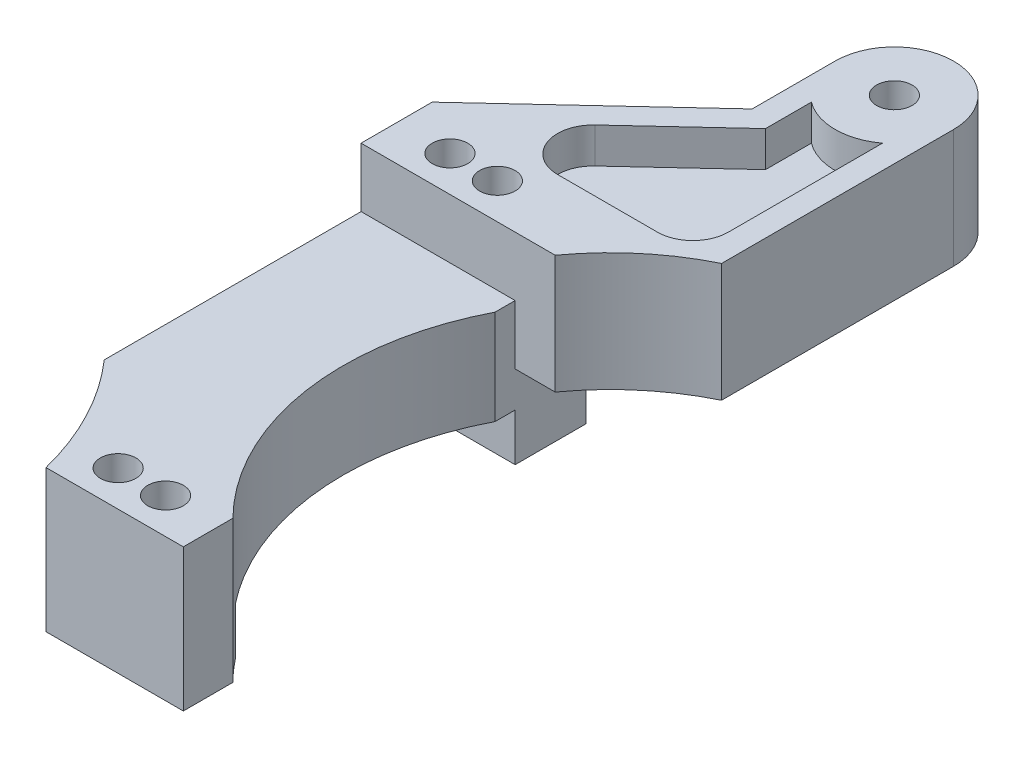
from build123d import *

# Parameters (mm, degrees)
SKETCH1_W               = 13
SKETCH1_H               = 6
SKETCH1_R               = 1.5
BOSS_EXTRUDE1_DEPTH     = 4
BOSS_EXTRUDE1_2_DEPTH   = 4
BOSS_EXTRUDE2_START     = 4
SKETCH1_4_R             = 1.5
SKETCH1_4_W             = 13
SKETCH1_4_H             = 6
BOSS_EXTRUDE2_DEPTH     = 8
SKETCH2_R               = 1.5
BOSS_EXTRUDE3_DEPTH     = 5
SKETCH2_3_R             = 1.5
BOSS_EXTRUDE4_DEPTH     = 5
CUT_EXTRUDE1_DEPTH      = 3
FILLET3_R               = 3
SKETCH4_R               = 20.5
CUT_EXTRUDE2_DEPTH      = 6
CUT_EXTRUDE2_DEPTH_BACK = 13


with BuildPart() as part:
    # Sketch1 → Boss-Extrude1 (new body)
    with BuildSketch(Plane(origin=(0, -9, 0), x_dir=(1, 0, 0), z_dir=(0, 1, 0))):
        with Locations((25.1, 41)):
            Rectangle(SKETCH1_W, SKETCH1_H)
        with Locations((27.1, 41)):
            Circle(SKETCH1_R, mode=Mode.SUBTRACT)
        with Locations((23.1, 41)):
            Circle(SKETCH1_R, mode=Mode.SUBTRACT)
    extrude(amount=BOSS_EXTRUDE1_DEPTH)



with BuildPart() as body_2:
    # Sketch1 → Boss-Extrude1 2 (new body)
    with BuildSketch(Plane(origin=(0, -9, 0), x_dir=(1, 0, 0), z_dir=(0, 1, 0))):
        with BuildLine():
            ThreePointArc((22.6, 10.089722494), (23.395394249, 8.075767946), (24.01171589, 6))
            Line((24.01171589, 6), (35.6, 6))
            Line((35.6, 6), (35.6, 10.18070798))
            ThreePointArc((35.6, 10.18070798), (34.768444056, 11.068532406), (33.986085046, 12))
            Line((33.986085046, 12), (31.6, 12))
            Line((31.6, 12), (22.6, 12))
            Line((22.6, 12), (22.6, 10.089722494))
        make_face()
        with Locations((27.1, 9)):
            Circle(SKETCH1_R, mode=Mode.SUBTRACT)
        with Locations((31.1, 9)):
            Circle(SKETCH1_R, mode=Mode.SUBTRACT)
    extrude(amount=BOSS_EXTRUDE1_2_DEPTH)


with BuildPart() as part_1:
    add(part.part)

    add(body_2.part)  # Boss-Extrude2 merges body 2
    # Sketch1_4 → Boss-Extrude2 (add)
    with BuildSketch(Plane(origin=(0, -9, 0), x_dir=(1, 0, 0), z_dir=(0, 1, 0)).offset(BOSS_EXTRUDE2_START)):
        with BuildLine():
            ThreePointArc((22.6, 10.089722494), (23.395394249, 8.075767946), (24.01171589, 6))
            Line((24.01171589, 6), (35.6, 6))
            Line((35.6, 6), (35.6, 10.18070798))
            ThreePointArc((35.6, 10.18070798), (34.768444056, 11.068532406), (33.986085046, 12))
            Line((33.986085046, 12), (31.6, 12))
            Line((31.6, 12), (22.6, 12))
            Line((22.6, 12), (22.6, 10.089722494))
        make_face()
        with Locations((27.1, 9)):
            Circle(SKETCH1_4_R, mode=Mode.SUBTRACT)
        with Locations((31.1, 9)):
            Circle(SKETCH1_4_R, mode=Mode.SUBTRACT)
        with BuildLine():
            Line((21.646304534, 12), (22.6, 12))
            Line((22.6, 12), (31.6, 12))
            Line((31.6, 12), (31.6, 15.692235936))
            ThreePointArc((31.6, 15.692235936), (29.1, 26), (31.6, 36.307764064))
            Line((31.6, 36.307764064), (31.6, 38))
            Line((31.6, 38), (18.6, 38))
            Line((18.6, 38), (18.6, 16.327966805))
            ThreePointArc((18.6, 16.327966805), (20.239171953, 14.245645604), (21.646304534, 12))
        make_face()
        with BuildLine():
            Line((31.6, 15.692235936), (31.6, 12))
            Line((31.6, 12), (33.986085046, 12))
            ThreePointArc((33.986085046, 12), (32.702650951, 13.787702963), (31.6, 15.692235936))
        make_face()
        with BuildLine():
            ThreePointArc((21.646304534, 12), (22.143761114, 11.055150099), (22.6, 10.089722494))
            Line((22.6, 10.089722494), (22.6, 12))
            Line((22.6, 12), (21.646304534, 12))
        make_face()
        with Locations((25.1, 41)):
            Rectangle(SKETCH1_4_W, SKETCH1_4_H)
        with Locations((27.1, 41)):
            Circle(SKETCH1_4_R, mode=Mode.SUBTRACT)
        with Locations((23.1, 41)):
            Circle(SKETCH1_4_R, mode=Mode.SUBTRACT)
    extrude(amount=BOSS_EXTRUDE2_DEPTH)

    # Sketch2 → Boss-Extrude3 (add)
    with BuildSketch(Plane(origin=(0, 3, 0), x_dir=(1, 0, 0), z_dir=(0, 1, 0))):
        with BuildLine():
            ThreePointArc((32.6, 64), (37.6, 69), (42.6, 64))
            Line((42.6, 64), (42.6, 43))
            ThreePointArc((42.6, 43), (37.6, 38), (32.6, 43))
            Line((32.6, 43), (32.6, 64))
        make_face()
        with Locations((37.6, 64)):
            Circle(SKETCH2_R, mode=Mode.SUBTRACT)
        Polygon((24.675471698, 49.641509434), (30.1, 44), (31.6, 44), (32.6, 44), (32.6, 57), align=None)
        Polygon((24.675471698, 49.641509434), (18.6, 44), (30.1, 44), align=None)
        Polygon((30.1, 44), (18.6, 44), (18.6, 38), (31.6, 38), (31.6, 44), align=None)
        with Locations((23.1, 41)):
            Circle(SKETCH2_R, mode=Mode.SUBTRACT)
        with Locations((27.1, 41)):
            Circle(SKETCH2_R, mode=Mode.SUBTRACT)
        with BuildLine():
            Line((32.6, 43), (32.6, 38))
            Line((32.6, 38), (37.6, 38))
            ThreePointArc((37.6, 38), (34.064466094, 39.464466094), (32.6, 43))
        make_face()
        Polygon((32.6, 44), (31.6, 44), (31.6, 38), (32.6, 38), (32.6, 43), align=None)
    extrude(amount=BOSS_EXTRUDE3_DEPTH)

    # Sketch2_3 → Boss-Extrude4 (add)
    with BuildSketch(Plane(origin=(0, 3, 0), x_dir=(1, 0, 0), z_dir=(0, 1, 0))):
        with BuildLine():
            ThreePointArc((32.6, 64), (37.6, 69), (42.6, 64))
            Line((42.6, 64), (42.6, 43))
            ThreePointArc((42.6, 43), (37.6, 38), (32.6, 43))
            Line((32.6, 43), (32.6, 64))
        make_face()
        with Locations((37.6, 64)):
            Circle(SKETCH2_3_R, mode=Mode.SUBTRACT)
        Polygon((24.675471698, 49.641509434), (30.1, 44), (31.6, 44), (32.6, 44), (32.6, 57), align=None)
        Polygon((24.675471698, 49.641509434), (18.6, 44), (30.1, 44), align=None)
        Polygon((32.6, 44), (31.6, 44), (31.6, 38), (32.6, 38), (32.6, 43), align=None)
        with BuildLine():
            Line((32.6, 43), (32.6, 38))
            Line((32.6, 38), (37.6, 38))
            ThreePointArc((37.6, 38), (34.064466094, 39.464466094), (32.6, 43))
        make_face()
    extrude(amount=-BOSS_EXTRUDE4_DEPTH)

    # Sketch3 → Cut-Extrude1 (cut)
    with BuildSketch(Plane(origin=(0, 8, 0), x_dir=(1, 0, 0), z_dir=(0, 1, 0))):
        with BuildLine():
            Line((34.6, 60), (34.6, 56.127860975))
            Line((34.6, 56.127860975), (21.539226642, 44))
            Line((21.539226642, 44), (40.6, 44))
            Line((40.6, 44), (40.6, 60))
            ThreePointArc((40.6, 60), (37.6, 59), (34.6, 60))
        make_face()
    extrude(amount=-CUT_EXTRUDE1_DEPTH, mode=Mode.SUBTRACT)

    # Fillet3
    fillet3_edges = [part_1.edges().sort_by_distance(p)[0] for p in [
        (40.6, 6.5, -44),
        (21.539226642, 6.5, -44),
    ]]
    fillet(fillet3_edges, radius=FILLET3_R)

    # Sketch4 → Cut-Extrude2 (cut, two sides)
    with BuildSketch(Plane(origin=(0, 3, 0), x_dir=(1, 0, 0), z_dir=(0, 1, 0))) as cut_extrude2_sk:
        with Locations((51.6, 26)):
            Circle(SKETCH4_R)
    extrude(amount=CUT_EXTRUDE2_DEPTH, mode=Mode.SUBTRACT)
    extrude(cut_extrude2_sk.sketch, amount=-CUT_EXTRUDE2_DEPTH_BACK, mode=Mode.SUBTRACT)


solid = part_1.part
